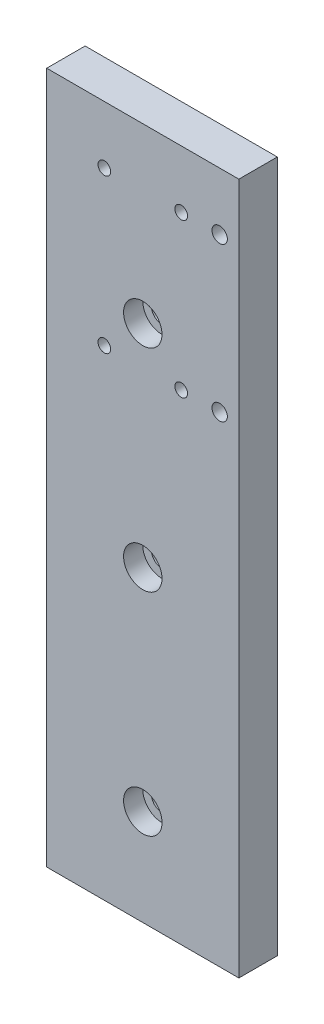
from build123d import *

# Parameters (mm, degrees)
SKETCH1_W             = 50
SKETCH1_H             = 180
SKETCH1_R             = 2.75
SKETCH1_R_2           = 2
BOSS_EXTRUDE1_DEPTH   = 10
SKETCH2_R             = 5
CUT_EXTRUDE1_DEPTH    = 5
M4_TAPPED_HOLE1_D     = 3.3
M4_TAPPED_HOLE2_D     = 3.3
M4_TAPPED_HOLE2_DEPTH = 8
M4_TAPPED_HOLE2_TIP   = 0.991420021


with BuildPart() as part:
    # Sketch1 → Boss-Extrude1 (new body)
    with BuildSketch(Plane.XY):
        with Locations((-10.981308411, -54.193925234)):
            Rectangle(SKETCH1_W, SKETCH1_H)
        with Locations((-10.981308411, -119.193925234)):
            Circle(SKETCH1_R, mode=Mode.SUBTRACT)
        with Locations((-10.981308411, -64.193925234)):
            Circle(SKETCH1_R, mode=Mode.SUBTRACT)
        with Locations((-10.981308411, -9.193925234)):
            Circle(SKETCH1_R, mode=Mode.SUBTRACT)
        with Locations((9.018691589, 20.806074766)):
            Circle(SKETCH1_R_2, mode=Mode.SUBTRACT)
        with Locations((9.018691589, -19.193925234)):
            Circle(SKETCH1_R_2, mode=Mode.SUBTRACT)
    extrude(amount=BOSS_EXTRUDE1_DEPTH)

    # Sketch2 → Cut-Extrude1 (cut)
    with BuildSketch(Plane.XY.offset(10)):
        with Locations((-10.981308411, -9.193925234)):
            Circle(SKETCH2_R)
        with Locations((-10.981308411, -64.193925234)):
            Circle(SKETCH2_R)
        with Locations((-10.981308411, -119.193925234)):
            Circle(SKETCH2_R)
    extrude(amount=-CUT_EXTRUDE1_DEPTH, mode=Mode.SUBTRACT)

    # M4 Tapped Hole1 (through all)
    with Locations(Plane.XY.offset(10)):
        with Locations((-0.981308411, -19.193925234), (-20.981308411, -19.193925234), (-20.981308411, 20.806074766), (-0.981308411, 20.806074766)):
            Hole(M4_TAPPED_HOLE1_D / 2)

    # M4 Tapped Hole2
    with Locations(Plane(origin=(0, -144.193925234, 0), x_dir=(-1, 0, 0), z_dir=(0, -1, 0))):
        with Locations((29.981308411, -5), (-8.018691589, -5)):
            Hole(M4_TAPPED_HOLE2_D / 2, depth=M4_TAPPED_HOLE2_DEPTH)
            with Locations((0, 0, -(M4_TAPPED_HOLE2_DEPTH + M4_TAPPED_HOLE2_TIP / 2))):  # 118° drill point
                Cone(0, M4_TAPPED_HOLE2_D / 2, M4_TAPPED_HOLE2_TIP, mode=Mode.SUBTRACT)


solid = part.part
